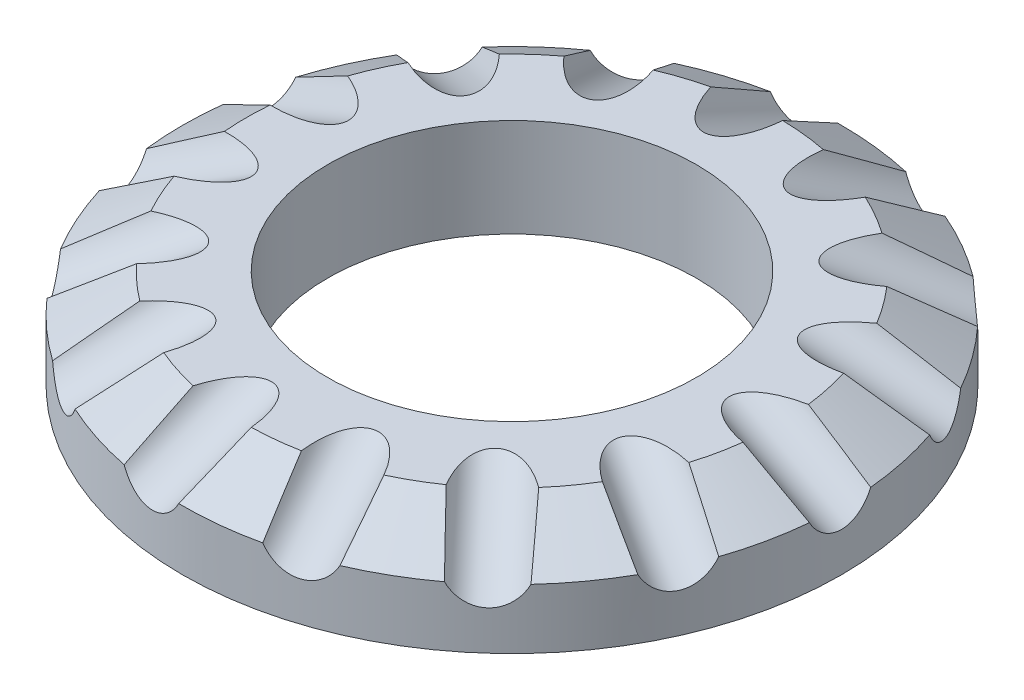
from build123d import *

# Parameters (mm, degrees)
KREISMUSTER1_COUNT = 15


with BuildPart() as part:
    # Skizze1 → Rotation1 (revolve)
    with BuildSketch(Plane.XY, mode=Mode.PRIVATE) as rotation1_sk:
        Polygon((16.14475863, 0), (16.14475863, 8.608081897), (23.261403386, 8.608081897), (28.845024076, 5.234644397), (28.845024076, 0), align=None)
    revolve(rotation1_sk.sketch.rotate(Axis((0, 0, 0), (0, 1, 0)), 90), axis=Axis((0, 0, 0), (0, 1, 0)))  # turned: the seam where the file's is

    # Skizze2 → Schnitt-Rotation1 (revolve, cut)
    with BuildSketch(Plane.XY):
        Polygon((18.433980943, 12.441833146), (35.219041201, 3.611138793), (33.767638602, 0.852365915), (16.982578344, 9.683060267), align=None)
    schnitt_rotation1 = revolve(axis=Axis((14.262929412, 14.636241782, 0), (0.884995308, -0.465599941, 0)), mode=Mode.SUBTRACT)

    # Kreismuster1: Schnitt-Rotation1 ×15 about axis
    kreismuster1_axis = Axis((0, 0, 0), (0, -1, 0))
    for i in range(1, KREISMUSTER1_COUNT):
        add(schnitt_rotation1.rotate(kreismuster1_axis, i * 360 / KREISMUSTER1_COUNT), mode=Mode.SUBTRACT)


solid = part.part
